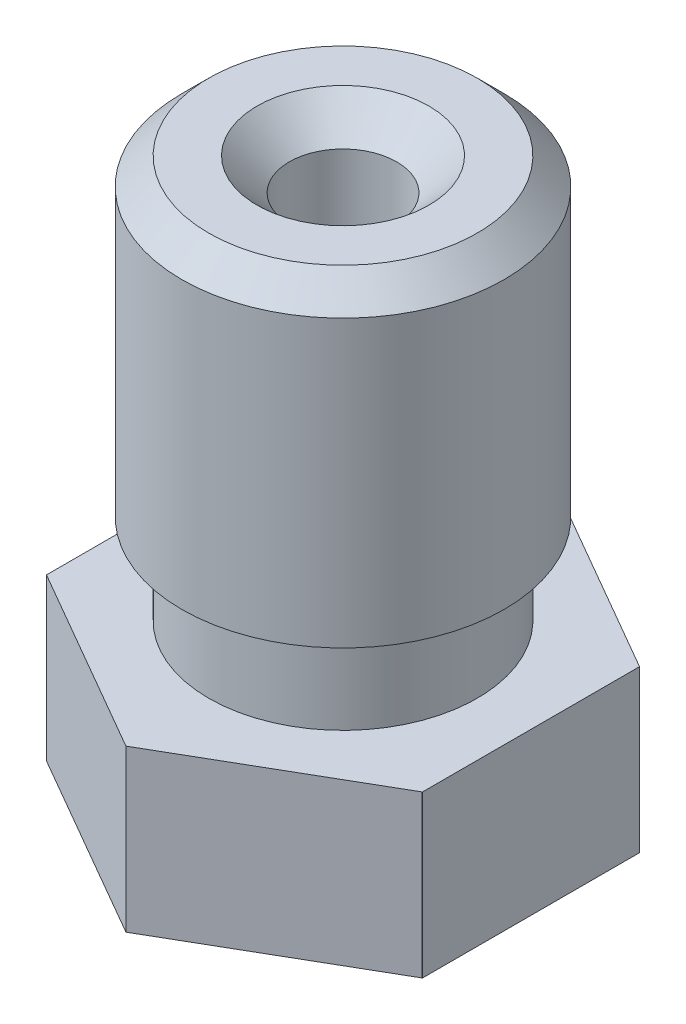
from build123d import *

# Parameters (mm, degrees)
SKETCH_2_OUTSIDE_W  = 13.468
SKETCH_2_OUTSIDE_H  = 13.468
CUT_EXTRUDE_1_DEPTH = 3
CHAMFER_1_SIZE      = 0.6


with BuildPart() as part:
    # Эскиз1 → Повернуть1 (revolve)
    with BuildSketch(Plane(origin=(0, 0, 0), x_dir=(0, 0, -1), z_dir=(1, 0, 0))):
        Polygon((-0.4, 0.8), (-0.4, 0), (-0.5, 0), (-1.900415076, 2), (-4.04, 2), (-4.04, 5), (-2.5, 5), (-2.5, 6.5), (-3, 6.681985117), (-3, 12), (-2.5, 12.5), (-1, 12.5), (-1, 2), (-0.75, 1.849784845), (-0.75, 1.010301217), align=None)
    revolve(axis=Axis((0, 0, 0), (0, 1, 0)))

    # Эскиз2 outside → Вырез-Вытянуть1 (cut)
    with BuildSketch(Plane.XZ.offset(-2)):
        Rectangle(SKETCH_2_OUTSIDE_W, SKETCH_2_OUTSIDE_H)
        Polygon((0, 4.041451884), (-3.5, 2.020725942), (-3.5, -2.020725942), (0, -4.041451884), (3.5, -2.020725942), (3.5, 2.020725942), align=None, mode=Mode.SUBTRACT)
    extrude(amount=-CUT_EXTRUDE_1_DEPTH, mode=Mode.SUBTRACT)

    # Фаска1
    chamfer_1_edges = [part.edges().sort_by_distance(p)[0] for p in [
        (0, 12.5, -1),
    ]]
    chamfer(chamfer_1_edges, length=CHAMFER_1_SIZE)


solid = part.part
